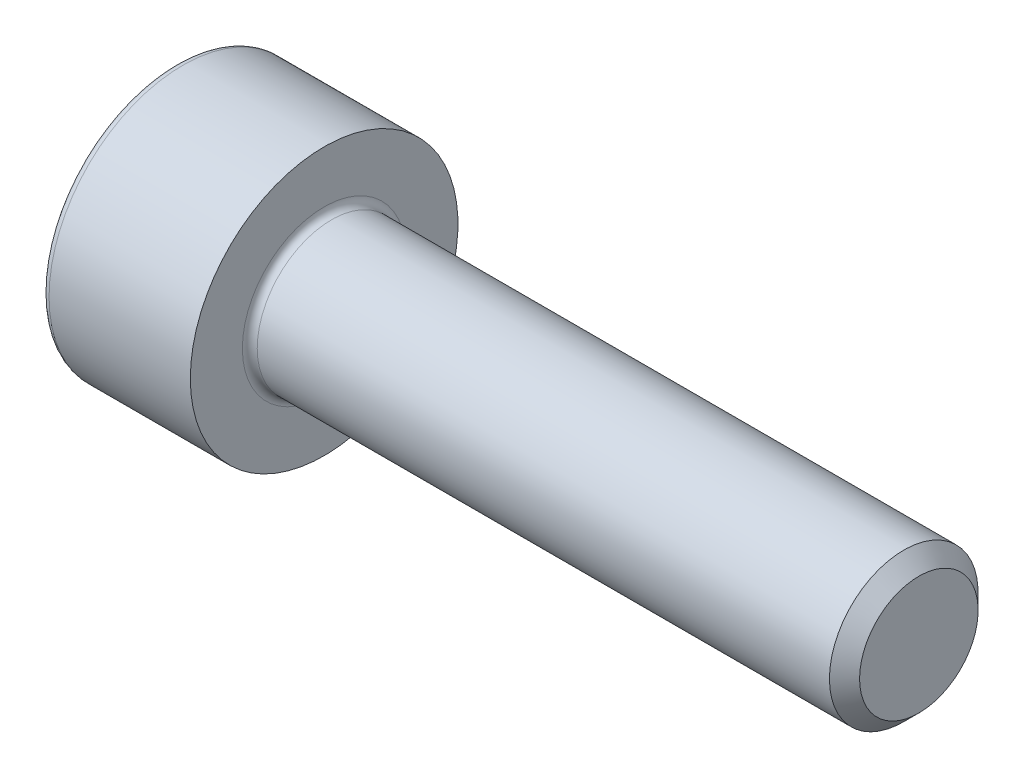
from build123d import *

# Parameters (mm, degrees)
CUT_EXTRUDE1_DEPTH = 1.1


with BuildPart() as part:
    # Sketch1 → Revolve1 (revolve)
    with BuildSketch(Plane.XY):
        with BuildLine():
            Line((9.7465, 1.25), (0.125, 1.25))
            ThreePointArc((0.125, 1.25), (0.036611652, 1.286611652), (0, 1.375))
            Line((0, 1.375), (0, 2.25))
            Line((0, 2.25), (-2.375, 2.25))
            ThreePointArc((-2.375, 2.25), (-2.463388348, 2.213388348), (-2.5, 2.125))
            Line((-2.5, 2.125), (-2.5, 0))
            Line((-2.5, 0), (10, 0))
            Line((10, 0), (10, 0.9965))
            Line((10, 0.9965), (9.7465, 1.25))
        make_face()
    revolve(axis=Axis((-2.5, 0, 0), (1, 0, 0)))

    # Sketch2 → Cut-Extrude1 (cut)
    with BuildSketch(Plane.ZY.offset(2.5)):
        Polygon((1.025, 0.591784026), (0, 1.183568052), (-1.025, 0.591784026), (-1.025, -0.591784026), (0, -1.183568052), (1.025, -0.591784026), align=None)
    extrude(amount=-CUT_EXTRUDE1_DEPTH, mode=Mode.SUBTRACT)


solid = part.part
